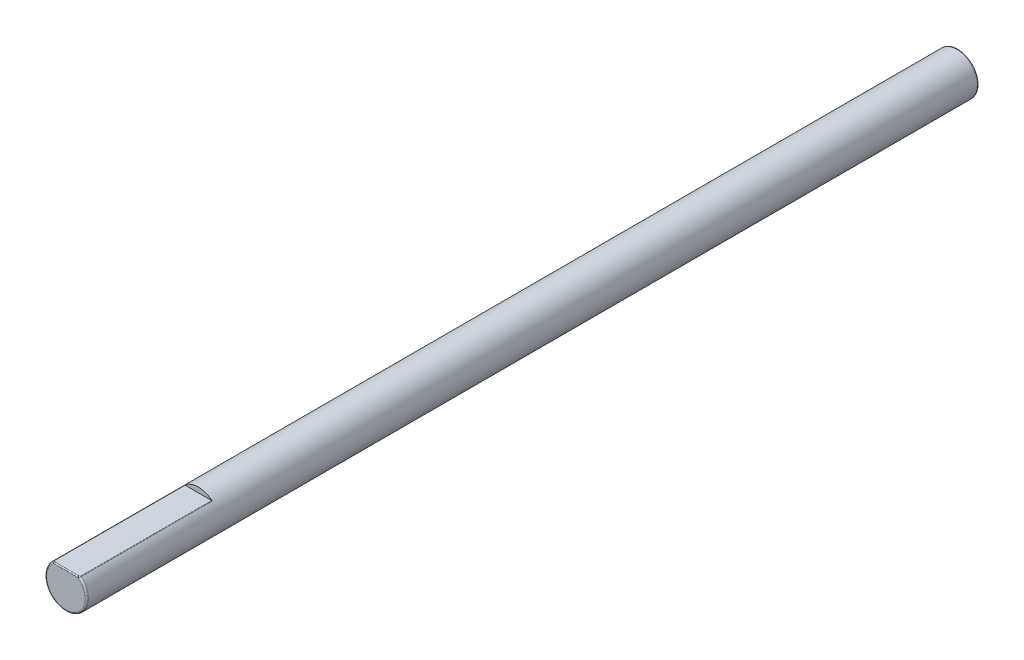
from build123d import *

# Parameters (mm, degrees)
SKETCH1_R               = 1.57734
BOSS_EXTRUDE1_DEPTH     = 67.564
FILLET1_R               = 0.127
CUT_EXTRUDE1_DEPTH      = 68.600814341
CUT_EXTRUDE1_DEPTH_BACK = 68.600814341
FILLET2_R               = 0.0762


with BuildPart() as part:
    # Sketch1 → Boss-Extrude1 (new body)
    with BuildSketch(Plane.XY):
        Circle(SKETCH1_R)
    extrude(amount=BOSS_EXTRUDE1_DEPTH)

    # Fillet1
    fillet1_edges = [part.edges().sort_by_distance(p)[0] for p in [
        (-1.57734, 0, 0),
        (-1.57734, 0, 67.564),
    ]]
    fillet(fillet1_edges, radius=FILLET1_R)

    # Sketch2 → Cut-Extrude1 (cut, two sides)
    with BuildSketch(Plane(origin=(0, 0, 0), x_dir=(0, 0, -1), z_dir=(1, 0, 0))) as cut_extrude1_sk:
        with BuildLine():
            Line((-57.531, 1.57734), (-67.437, 1.57734))
            ThreePointArc((-67.437, 1.57734), (-67.526802561, 1.540142561), (-67.564, 1.45034))
            Line((-67.564, 1.45034), (-67.564, 1.19634))
            Line((-67.564, 1.19634), (-57.531, 1.19634))
            Line((-57.531, 1.19634), (-57.531, 1.57734))
        make_face()
    extrude(amount=CUT_EXTRUDE1_DEPTH, mode=Mode.SUBTRACT)
    extrude(cut_extrude1_sk.sketch, amount=-CUT_EXTRUDE1_DEPTH_BACK, mode=Mode.SUBTRACT)

    # Fillet2
    fillet2_edges = [part.edges().sort_by_distance(p)[0] for p in [
        (0.950300299, 1.19634, 67.537610624),
        (0, 1.19634, 67.564),
        (-1.027994202, 1.19634, 62.484),
        (1.027994202, 1.19634, 62.484),
        (0, 1.19634, 67.564),
    ]]
    fillet(fillet2_edges, radius=FILLET2_R)


solid = part.part
